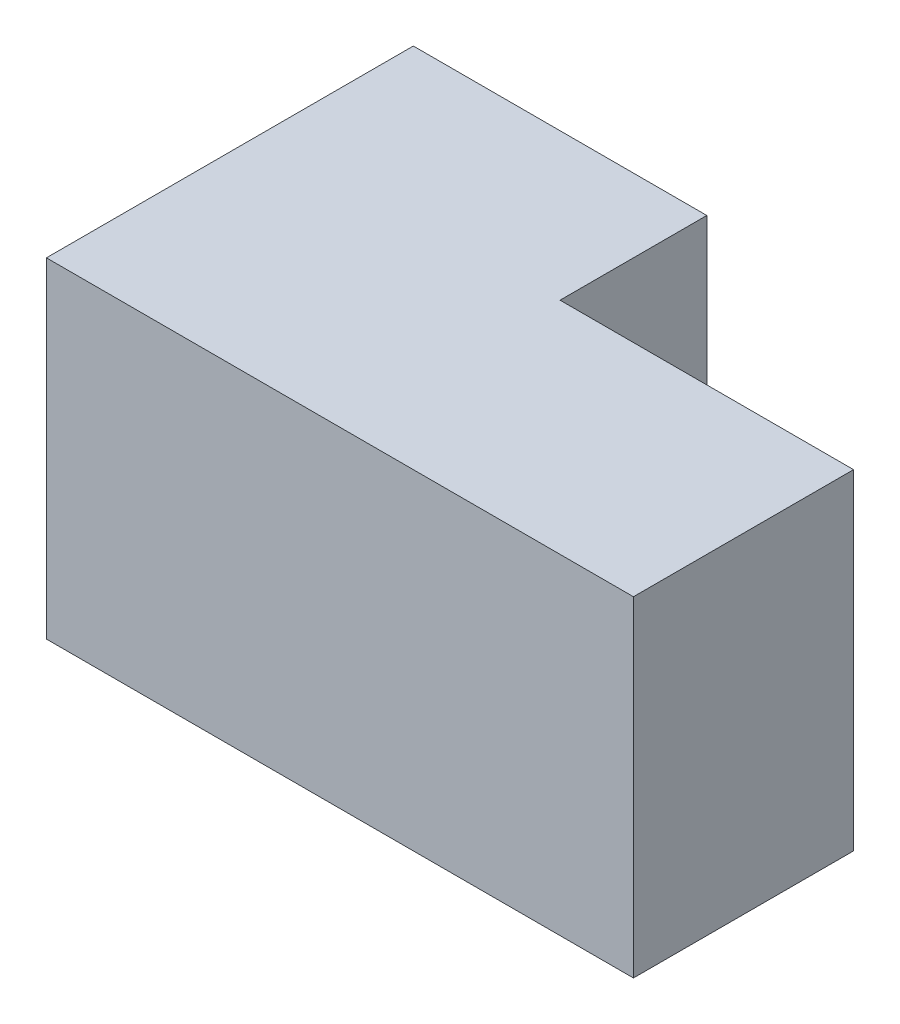
from build123d import *

# Parameters (mm, degrees)
BOSS_EXTRUDE1_DEPTH = 28.575


with BuildPart() as part:
    # Sketch1 → Boss-Extrude1 (new body)
    with BuildSketch(Plane(origin=(0, 0, 0), x_dir=(1, 0, 0), z_dir=(0, 1, 0))):
        Polygon((0, 31.75), (0, 0), (50.8, 0), (50.8, 19.05), (25.4, 19.05), (25.4, 31.75), align=None)
    extrude(amount=BOSS_EXTRUDE1_DEPTH)


solid = part.part
